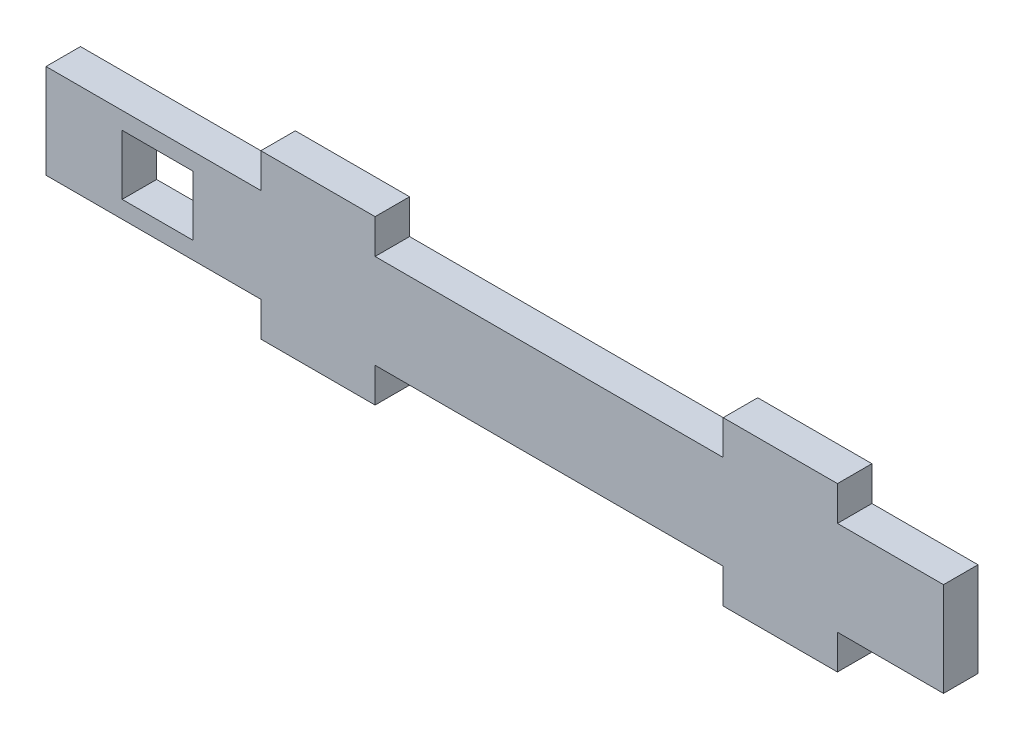
from build123d import *

# Parameters (mm, degrees)
SKETCH1_W           = 6.5
SKETCH1_H           = 5.5
BOSS_EXTRUDE1_DEPTH = 3.17


with BuildPart() as part:
    # Sketch1 → Boss-Extrude1 (new body)
    with BuildSketch(Plane.XY):
        Polygon((0, 8.66), (0, 0), (19.75, 0), (19.75, -3.17), (30.25, -3.17), (30.25, 0), (62.25, 0), (62.25, -3.17), (72.75, -3.17), (72.75, 0), (82.5, 0), (82.5, 8.66), (72.75, 8.66), (72.75, 11.83), (62.25, 11.83), (62.25, 8.66), (30.25, 8.66), (30.25, 11.83), (19.75, 11.83), (19.75, 8.66), align=None)
        with Locations((10.25, 4.33)):
            Rectangle(SKETCH1_W, SKETCH1_H, mode=Mode.SUBTRACT)
    extrude(amount=BOSS_EXTRUDE1_DEPTH)


solid = part.part
